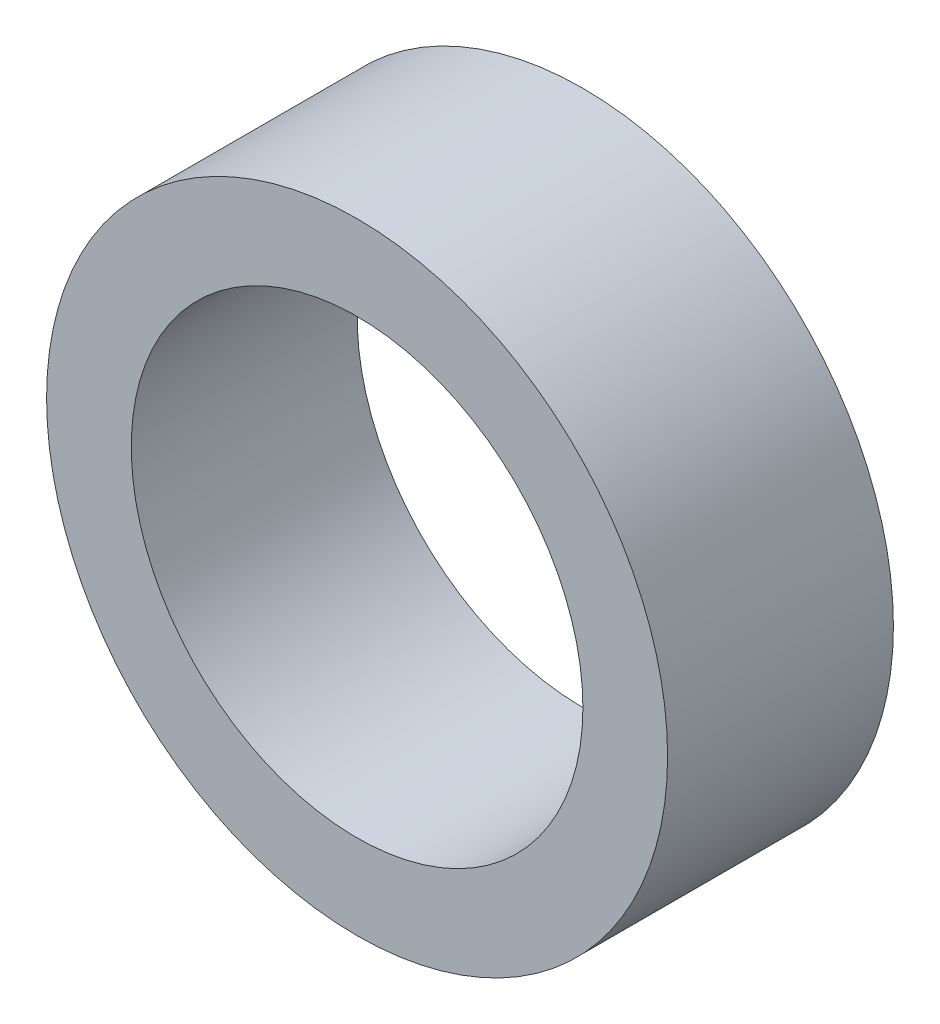
from build123d import *

# Parameters (mm, degrees)
CROQUIS1_R              = 11
CROQUIS1_R_2            = 8
SALIENTE_EXTRUIR1_DEPTH = 8


with BuildPart() as part:
    # Croquis1 → Saliente-Extruir1 (new body)
    with BuildSketch(Plane.XY):
        Circle(CROQUIS1_R)
        Circle(CROQUIS1_R_2, mode=Mode.SUBTRACT)
    extrude(amount=SALIENTE_EXTRUIR1_DEPTH)


solid = part.part
